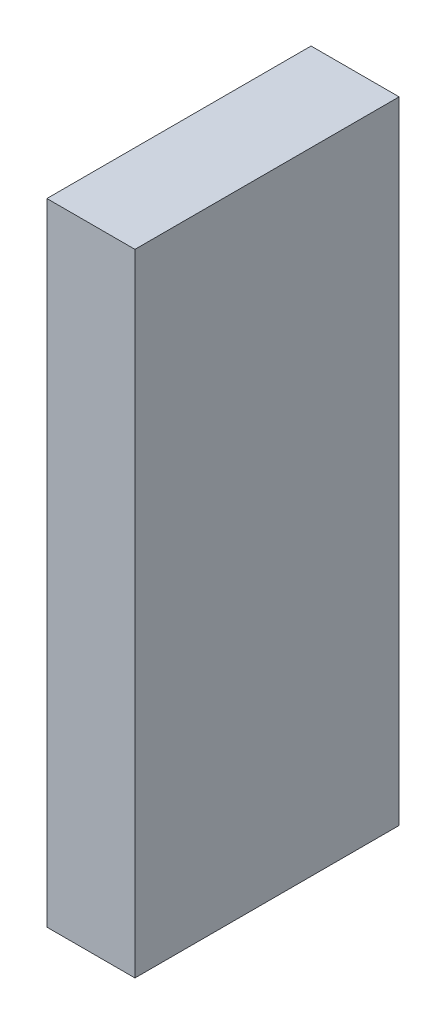
from build123d import *

# Parameters (mm, degrees)
SKETCH1_W           = 30
SKETCH1_H           = 90
BOSS_EXTRUDE1_DEPTH = 107.5


with BuildPart() as part:
    # Sketch1 → Boss-Extrude1 (new body, symmetric)
    with BuildSketch(Plane(origin=(0, 0, 0), x_dir=(1, 0, 0), z_dir=(0, 1, 0))):
        Rectangle(SKETCH1_W, SKETCH1_H)
    extrude(amount=BOSS_EXTRUDE1_DEPTH, both=True)


solid = part.part
